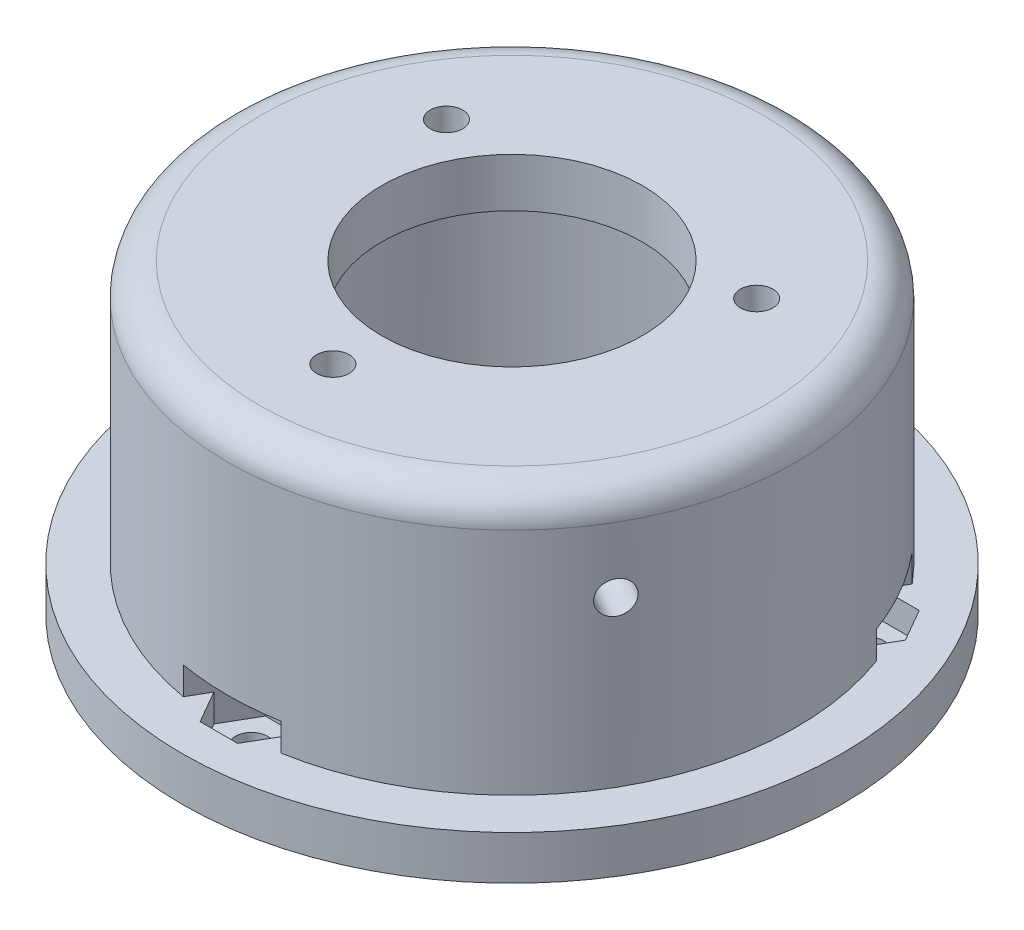
from build123d import *

# Parameters (mm, degrees)
SKETCH1_R                = 17.45
SKETCH1_R_2              = 12.45
BOSS_EXTRUDE1_DEPTH      = 8
BOSS_EXTRUDE1_DEPTH_BACK = 25
SKETCH1_2_R              = 17.45
SKETCH1_2_R_2            = 12.45
BOSS_EXTRUDE3_DEPTH      = 18
SKETCH3_R                = 12.45
SKETCH3_R_2              = 8
BOSS_EXTRUDE4_DEPTH      = 3
SKETCH4_R                = 1
CUT_EXTRUDE1_DEPTH       = 10
SKETCH6_R                = 13.5
CUT_EXTRUDE2_DEPTH       = 40
SKETCH7_R                = 1
CUT_EXTRUDE3_DEPTH       = 21
CIRPATTERN1_COUNT        = 3
BOSS_EXTRUDE5_START      = -16.1
SKETCH8_R                = 20.25
SKETCH8_R_2              = 13.5
BOSS_EXTRUDE5_DEPTH      = 3
FILLET1_R                = 2
SKETCH9_W                = 226.458017819
SKETCH9_H                = 42.937005292
CUT_EXTRUDE4_DEPTH       = 34
CUT_EXTRUDE4_DEPTH_BACK  = 62
CUT_EXTRUDE5_START       = -1.9
CUT_EXTRUDE5_DEPTH       = 1.7
CUT_EXTRUDE5_DEPTH_BACK  = 1.3
SKETCH11_R               = 1
CUT_EXTRUDE6_DEPTH       = 3
CUT_EXTRUDE7_START       = -1.9
CUT_EXTRUDE7_DEPTH       = 1.7
SKETCH14_R               = 20.25
SKETCH14_R_2             = 1
SKETCH14_R_3             = 13.5
BOSS_EXTRUDE6_DEPTH      = 0.8


with BuildPart() as part:
    # Sketch1 → Boss-Extrude1 (new body, two sides)
    with BuildSketch(Plane(origin=(0, 0, 0), x_dir=(1, 0, 0), z_dir=(0, 1, 0))) as boss_extrude1_sk:
        Circle(SKETCH1_R)
        Circle(SKETCH1_R_2, mode=Mode.SUBTRACT)
    extrude(amount=BOSS_EXTRUDE1_DEPTH)
    extrude(boss_extrude1_sk.sketch, amount=-BOSS_EXTRUDE1_DEPTH_BACK)

    # Sketch1_2 → Boss-Extrude3 (add)
    with BuildSketch(Plane(origin=(0, 0, 0), x_dir=(1, 0, 0), z_dir=(0, 1, 0))):
        Circle(SKETCH1_2_R)
        Circle(SKETCH1_2_R_2, mode=Mode.SUBTRACT)
    extrude(amount=BOSS_EXTRUDE3_DEPTH)

    # Sketch3 → Boss-Extrude4 (add)
    with BuildSketch(Plane(origin=(0, 18, 0), x_dir=(1, 0, 0), z_dir=(0, 1, 0))):
        Circle(SKETCH3_R)
        Circle(SKETCH3_R_2, mode=Mode.SUBTRACT)
    extrude(amount=-BOSS_EXTRUDE4_DEPTH)

    # Sketch4 → Cut-Extrude1 (cut)
    with BuildSketch(Plane(origin=(0, 18, 0), x_dir=(1, 0, 0), z_dir=(0, 1, 0))):
        with Locations((9.526279442, 5.5)):
            Circle(SKETCH4_R)
        with Locations((-9.526279442, 5.5)):
            Circle(SKETCH4_R)
        with Locations((0, -11)):
            Circle(SKETCH4_R)
    extrude(amount=-CUT_EXTRUDE1_DEPTH, mode=Mode.SUBTRACT)

    # Sketch6 → Cut-Extrude2 (cut)
    with BuildSketch(Plane.XZ.offset(25)):
        Circle(SKETCH6_R)
    extrude(amount=-CUT_EXTRUDE2_DEPTH, mode=Mode.SUBTRACT)

    # Sketch7 → Cut-Extrude3 (cut)
    with BuildSketch(Plane.XY):
        with Locations((0, 12)):
            Circle(SKETCH7_R)
    cut_extrude3 = extrude(amount=-CUT_EXTRUDE3_DEPTH, mode=Mode.SUBTRACT)

    # CirPattern1: Cut-Extrude3 ×3 about axis
    cirpattern1_axis = Axis((0, 53.183766184, 0), (0, -1, 0))
    for i in range(1, CIRPATTERN1_COUNT):
        add(cut_extrude3.rotate(cirpattern1_axis, i * 360 / CIRPATTERN1_COUNT), mode=Mode.SUBTRACT)

    # Sketch8 → Boss-Extrude5 (add)
    with BuildSketch(Plane(origin=(0, 18, 0), x_dir=(1, 0, 0), z_dir=(0, 1, 0)).offset(BOSS_EXTRUDE5_START)):
        Circle(SKETCH8_R)
        Circle(SKETCH8_R_2, mode=Mode.SUBTRACT)
    extrude(amount=-BOSS_EXTRUDE5_DEPTH)

    # Fillet1
    fillet1_edges = [part.edges().sort_by_distance(p)[0] for p in [
        (-17.45, 18, 0),
    ]]
    fillet(fillet1_edges, radius=FILLET1_R)

    # Sketch9 → Cut-Extrude4 (cut, two sides)
    with BuildSketch(Plane(origin=(0, 0, 0), x_dir=(0, 0, -1), z_dir=(1, 0, 0))) as cut_extrude4_sk:
        with Locations((-4.854722567, -21.468502646)):
            Rectangle(SKETCH9_W, SKETCH9_H)
    extrude(amount=CUT_EXTRUDE4_DEPTH, mode=Mode.SUBTRACT)
    extrude(cut_extrude4_sk.sketch, amount=-CUT_EXTRUDE4_DEPTH_BACK, mode=Mode.SUBTRACT)

    # Sketch10 → Cut-Extrude5 (cut, two sides)
    with BuildSketch(Plane.XZ.offset(CUT_EXTRUDE5_START)) as cut_extrude5_sk:
        Polygon((12.701705922, -10), (15.011106999, -10), (16.165807537, -8), (15.011106999, -6), (12.701705922, -6), (11.547005384, -8), align=None)
        Polygon((-15.011106999, -6), (-16.165807537, -8), (-15.011106999, -10), (-12.701705922, -10), (-11.547005384, -8), (-12.701705922, -6), align=None)
        Polygon((-1.154700538, 18), (-2.309401077, 16), (-1.154700538, 14), (1.154700538, 14), (2.309401077, 16), (1.154700538, 18), align=None)
    extrude(amount=CUT_EXTRUDE5_DEPTH, mode=Mode.SUBTRACT)
    extrude(cut_extrude5_sk.sketch, amount=-CUT_EXTRUDE5_DEPTH_BACK, mode=Mode.SUBTRACT)

    # Sketch11 → Cut-Extrude6 (cut)
    with BuildSketch(Plane.XZ):
        with Locations((0, 16)):
            Circle(SKETCH11_R)
        with Locations((13.856406461, -8)):
            Circle(SKETCH11_R)
        with Locations((-13.856406461, -8)):
            Circle(SKETCH11_R)
    extrude(amount=-CUT_EXTRUDE6_DEPTH, mode=Mode.SUBTRACT)

    # Sketch13 → Cut-Extrude7 (cut)
    with BuildSketch(Plane.XZ.offset(CUT_EXTRUDE7_START)):
        Polygon((13.856406461, -12), (17.320508076, -6), (12.701705922, -6), (11.547005384, -8), align=None)
        Polygon((-17.064341974, -5.610617289), (-14.321704831, -11.972845004), (-11.562683328, -8.268640139), (-12.476895709, -6.147897568), align=None)
        Polygon((-3.464101615, 18), (-1.154700538, 14), (1.154700538, 14), (3.464101615, 18), align=None)
    extrude(amount=-CUT_EXTRUDE7_DEPTH, mode=Mode.SUBTRACT)

    # Sketch14 → Boss-Extrude6 (add)
    with BuildSketch(Plane.XZ):
        Circle(SKETCH14_R)
        with Locations((0, 16)):
            Circle(SKETCH14_R_2, mode=Mode.SUBTRACT)
        with Locations((13.856406461, -8)):
            Circle(SKETCH14_R_2, mode=Mode.SUBTRACT)
        with Locations((-13.856406461, -8)):
            Circle(SKETCH14_R_2, mode=Mode.SUBTRACT)
        Circle(SKETCH14_R_3, mode=Mode.SUBTRACT)
    extrude(amount=BOSS_EXTRUDE6_DEPTH)


solid = part.part
